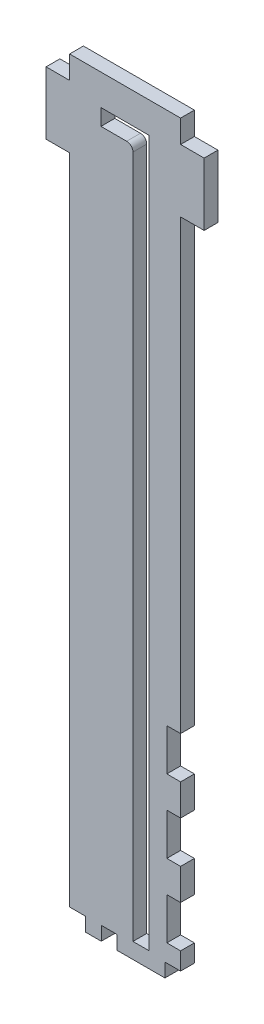
from build123d import *

# Parameters (mm, degrees)
SKETCH1_W           = 44.958
SKETCH1_H           = 304.8
BOSS_EXTRUDE1_DEPTH = 5.588
SKETCH2_W           = 5.588
SKETCH2_H           = 101.6
BOSS_EXTRUDE2_DEPTH = 5.588
SKETCH3_W           = 222.25
SKETCH3_H           = 5.588
BOSS_EXTRUDE3_DEPTH = 39.37
SKETCH7_W           = 327.022738736
SKETCH7_H           = 279.435650021
CUT_EXTRUDE1_DEPTH  = 45.958
SKETCH4_W           = 6.35
SKETCH4_H           = 5.588
SKETCH4_H_2         = 12.7
CUT_EXTRUDE2_DEPTH  = 5.588
SKETCH6_W           = 5.588
SKETCH6_H           = 16.933333333
SKETCH6_H_2         = 16.933333334
CUT_EXTRUDE3_DEPTH  = 6.588
SKETCH8_W           = 9.525
SKETCH8_H           = 25.4
BOSS_EXTRUDE4_DEPTH = 5.588


with BuildPart() as part:
    # Sketch1 → Boss-Extrude1 (new body)
    with BuildSketch(Plane.XY):
        with Locations((-6.477, 3.048)):
            Rectangle(SKETCH1_W, SKETCH1_H)
        with BuildLine():
            Line((-3.302, 133.858), (-3.302, -143.002))
            Line((-3.302, -143.002), (3.302, -143.002))
            Line((3.302, -143.002), (3.302, 143.002))
            Line((3.302, 143.002), (-16.256, 143.002))
            Line((-16.256, 143.002), (-16.256, 136.398))
            Line((-16.256, 136.398), (-5.842, 136.398))
            ThreePointArc((-5.842, 136.398), (-4.045948776, 135.654051224), (-3.302, 133.858))
        make_face(mode=Mode.SUBTRACT)
    extrude(amount=BOSS_EXTRUDE1_DEPTH)

    # Sketch2 → Boss-Extrude2 (add)
    with BuildSketch(Plane(origin=(16.002, 0, 0), x_dir=(0, 0, -1), z_dir=(1, 0, 0))):
        Polygon((222.25, -60.452), (222.25, -47.752), (0, -47.752), (0, -149.352), (222.25, -149.352), (222.25, -136.652), (228.6, -136.652), (228.6, -119.718666667), (222.25, -119.718666667), (222.25, -107.018666667), (228.6, -107.018666667), (228.6, -90.085333333), (222.25, -90.085333333), (222.25, -77.385333333), (228.6, -77.385333333), (228.6, -60.452), align=None)
        with BuildLine():
            ThreePointArc((11.4, -116.592), (9.9, -118.092), (8.4, -116.592))
            Line((8.4, -116.592), (8.4, -111.512))
            ThreePointArc((8.4, -111.512), (9.9, -110.012), (11.4, -111.512))
            Line((11.4, -111.512), (11.4, -116.592))
        make_face(mode=Mode.SUBTRACT)
        with BuildLine():
            Line((42.4, -111.512), (42.4, -116.592))
            ThreePointArc((42.4, -116.592), (40.9, -118.092), (39.4, -116.592))
            Line((39.4, -116.592), (39.4, -111.512))
            ThreePointArc((39.4, -111.512), (40.9, -110.012), (42.4, -111.512))
        make_face(mode=Mode.SUBTRACT)
        with BuildLine():
            ThreePointArc((36.4, -101.092), (25.4, -112.092), (14.4, -101.092))
            Line((14.4, -101.092), (14.4, -96.012))
            ThreePointArc((14.4, -96.012), (25.4, -85.012), (36.4, -96.012))
            Line((36.4, -96.012), (36.4, -101.092))
        make_face(mode=Mode.SUBTRACT)
        with BuildLine():
            ThreePointArc((11.4, -85.592), (9.9, -87.092), (8.4, -85.592))
            Line((8.4, -85.592), (8.4, -80.512))
            ThreePointArc((8.4, -80.512), (9.9, -79.012), (11.4, -80.512))
            Line((11.4, -80.512), (11.4, -85.592))
        make_face(mode=Mode.SUBTRACT)
        with BuildLine():
            ThreePointArc((42.4, -85.592), (40.9, -87.092), (39.4, -85.592))
            Line((39.4, -85.592), (39.4, -80.512))
            ThreePointArc((39.4, -80.512), (40.9, -79.012), (42.4, -80.512))
            Line((42.4, -80.512), (42.4, -85.592))
        make_face(mode=Mode.SUBTRACT)
        with Locations((-2.794, -98.552)):
            Rectangle(SKETCH2_W, SKETCH2_H)
    extrude(amount=-BOSS_EXTRUDE2_DEPTH)

    # Sketch3 → Boss-Extrude3 (add)
    with BuildSketch(Plane.ZY.offset(-10.414)):
        with Locations((-111.125, -146.558)):
            Rectangle(SKETCH3_W, SKETCH3_H)
    extrude(amount=BOSS_EXTRUDE3_DEPTH)

    # Sketch7 → Cut-Extrude1 (cut, through all)
    with BuildSketch(Plane(origin=(16.002, 0, 0), x_dir=(0, 0, -1), z_dir=(1, 0, 0))):
        with Locations((163.511369368, -148.348068682)):
            Rectangle(SKETCH7_W, SKETCH7_H)
    extrude(amount=-CUT_EXTRUDE1_DEPTH, mode=Mode.SUBTRACT)

    # Sketch4 → Cut-Extrude2 (cut)
    with BuildSketch(Plane.XZ.offset(149.352)):
        with Locations((-12.954, 2.794)):
            Rectangle(SKETCH4_W, SKETCH4_H)
        with Locations((12.827, 2.794)):
            Rectangle(SKETCH4_W, SKETCH4_H)
        with Locations((-25.781, 2.794)):
            Rectangle(SKETCH4_W, SKETCH4_H)
        with Locations((12.827, -135.22325)):
            Rectangle(SKETCH4_W, SKETCH4_H_2)
        with Locations((12.827, -54.5465)):
            Rectangle(SKETCH4_W, SKETCH4_H_2)
        with Locations((12.827, -162.1155)):
            Rectangle(SKETCH4_W, SKETCH4_H_2)
    extrude(amount=-CUT_EXTRUDE2_DEPTH, mode=Mode.SUBTRACT)

    # Sketch6 → Cut-Extrude3 (cut, through all)
    with BuildSketch(Plane.XY.offset(5.588)):
        with Locations((13.208, -68.918666667)):
            Rectangle(SKETCH6_W, SKETCH6_H)
        with Locations((13.208, -98.552)):
            Rectangle(SKETCH6_W, SKETCH6_H_2)
        with Locations((13.208, -128.185333334)):
            Rectangle(SKETCH6_W, SKETCH6_H)
    extrude(amount=-CUT_EXTRUDE3_DEPTH, mode=Mode.SUBTRACT)

    # Sketch8 → Boss-Extrude4 (add)
    with BuildSketch(Plane.XY.offset(5.588)):
        with Locations((-33.7185, 133.477)):
            Rectangle(SKETCH8_W, SKETCH8_H)
        with Locations((20.7645, 133.477)):
            Rectangle(SKETCH8_W, SKETCH8_H)
    extrude(amount=-BOSS_EXTRUDE4_DEPTH)


solid = part.part
